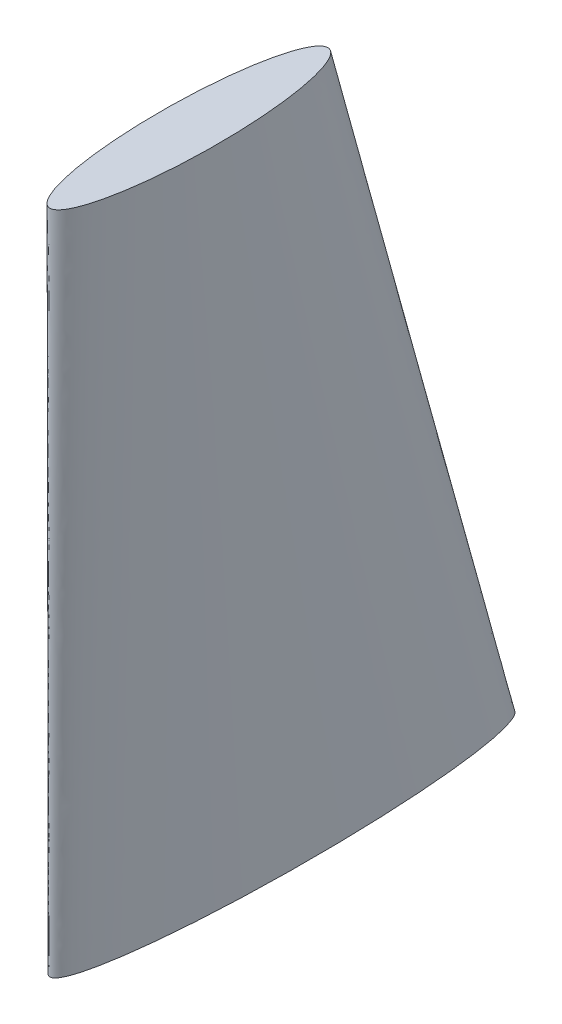
from build123d import *

# Parameters (mm, degrees)
SKETCH1_RX = 122.5
SKETCH1_RY = 15
SKETCH2_RX = 73.5
SKETCH2_RY = 15


with BuildPart() as part:
    # Sketch1 → Loft1 section 0
    with BuildSketch(Plane(origin=(0, 0, 0), x_dir=(1, 0, 0), z_dir=(0, 1, 0))):
        with Locations(Location((0, 0), (0, 0, 90))):
            Ellipse(SKETCH1_RX, SKETCH1_RY)
    # Sketch2 → Loft1 section 1
    with BuildSketch(Plane(origin=(0, 352, 0), x_dir=(1, 0, 0), z_dir=(0, 1, 0))):
        with Locations(Location((0, -49), (0, 0, -90))):
            Ellipse(SKETCH2_RX, SKETCH2_RY)
    loft()


solid = part.part
